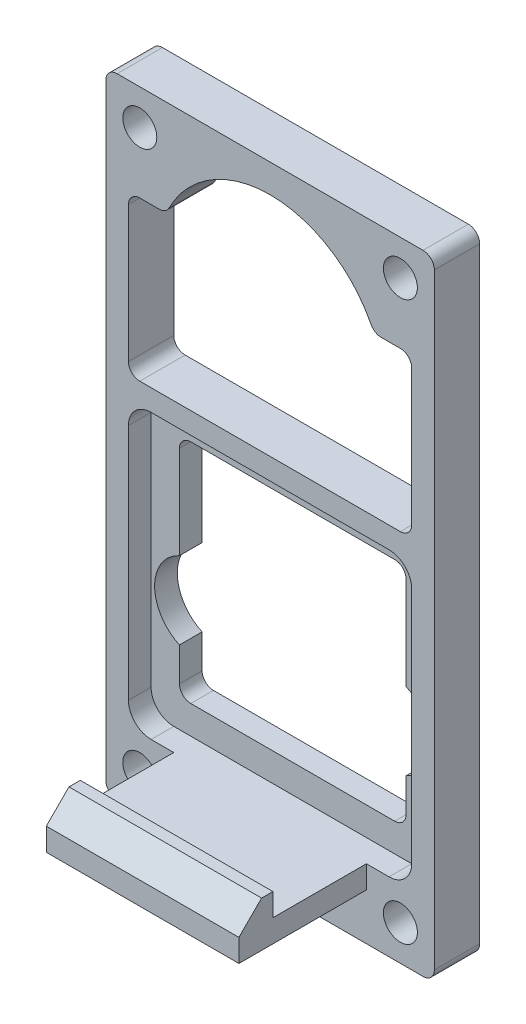
from build123d import *

# Parameters (mm, degrees)
SKETCH1_W             = 29
SKETCH1_H             = 55.5
BODY_DEPTH            = 4
SKETCH2_R             = 1.5
BOLT_HOLES_DEPTH      = 5
SERVO_CLEARANCE_DEPTH = 5
SKETCH4_W             = 25
SKETCH4_H             = 25
FAN_RECESS_DEPTH      = 2
CLAMP_FILLETS_R       = 1
FAN_FILLETS_R         = 2
SKETCH5_W             = 17
SKETCH5_H             = 2
CLAMP_BASE_DEPTH      = 8.25
CLAMP_HOOK_DEPTH      = 17


with BuildPart() as part:
    # Sketch1 → Body (new body)
    with BuildSketch(Plane.XY):
        with Locations((14.5, 27.75)):
            Rectangle(SKETCH1_W, SKETCH1_H)
    extrude(amount=BODY_DEPTH)

    # Sketch2 → Bolt Holes (cut, through all)
    with BuildSketch(Plane.XY.offset(4)):
        with Locations((3, 52.385)):
            Circle(SKETCH2_R)
        with Locations((26, 52.385)):
            Circle(SKETCH2_R)
        with Locations((26, 3.115)):
            Circle(SKETCH2_R)
        with Locations((3, 3.115)):
            Circle(SKETCH2_R)
    extrude(amount=-BOLT_HOLES_DEPTH, mode=Mode.SUBTRACT)

    # Sketch3 → Servo Clearance (cut, through all)
    with BuildSketch(Plane.XY.offset(4)):
        with BuildLine():
            Line((4.5, 12.5898827), (4.5, 8.615))
            Line((4.5, 8.615), (24.5, 8.615))
            Line((24.5, 8.615), (24.5, 12.5898827))
            ThreePointArc((24.5, 12.5898827), (26.69, 16), (24.5, 19.4101173))
            Line((24.5, 19.4101173), (24.5, 28.615))
            Line((24.5, 28.615), (4.5, 28.615))
            Line((4.5, 28.615), (4.5, 19.4101173))
            ThreePointArc((4.5, 19.4101173), (2.31, 16), (4.5, 12.5898827))
        make_face()
        with BuildLine():
            Line((2, 47), (5.33484861, 47))
            ThreePointArc((5.33484861, 47), (14.5, 53), (23.66515139, 47))
            Line((23.66515139, 47), (27, 47))
            Line((27, 47), (27, 33))
            Line((27, 33), (2, 33))
            Line((2, 33), (2, 47))
        make_face()
    extrude(amount=-SERVO_CLEARANCE_DEPTH, mode=Mode.SUBTRACT)

    # Sketch4 → Fan Recess (cut)
    with BuildSketch(Plane.XY.offset(4)):
        with Locations((14.5, 18.615)):
            Rectangle(SKETCH4_W, SKETCH4_H)
    extrude(amount=-FAN_RECESS_DEPTH, mode=Mode.SUBTRACT)

    # Clamp Fillets
    clamp_fillets_edges = [part.edges().sort_by_distance(p)[0] for p in [
        (4.5, 28.615, 1),
        (24.5, 28.615, 1),
        (24.5, 8.615, 1),
        (4.5, 8.615, 1),
        (2, 33, 2),
        (2, 47, 2),
        (5.33484861, 47, 2),
        (23.66515139, 47, 2),
        (27, 47, 2),
        (27, 33, 2),
        (0, 55.5, 2),
        (29, 55.5, 2),
        (29, 0, 2),
        (0, 0, 2),
    ]]
    fillet(clamp_fillets_edges, radius=CLAMP_FILLETS_R)

    # Fan Fillets
    fan_fillets_edges = [part.edges().sort_by_distance(p)[0] for p in [
        (27, 6.115, 3),
        (27, 31.115, 3),
        (2, 31.115, 3),
        (2, 6.115, 3),
    ]]
    fillet(fan_fillets_edges, radius=FAN_FILLETS_R)

    # Sketch5 → Clamp Base (add)
    with BuildSketch(Plane.XY.offset(4)):
        with Locations((14.5, 5.115)):
            Rectangle(SKETCH5_W, SKETCH5_H)
    extrude(amount=CLAMP_BASE_DEPTH)

    # Sketch7 → Clamp Hook (add)
    with BuildSketch(Plane.ZY.offset(-6)):
        Polygon((12.25, 4.115), (15.25, 4.115), (15.25, 6.115), (13.25, 8.115), (12.25, 8.115), align=None)
    extrude(amount=-CLAMP_HOOK_DEPTH)


solid = part.part
